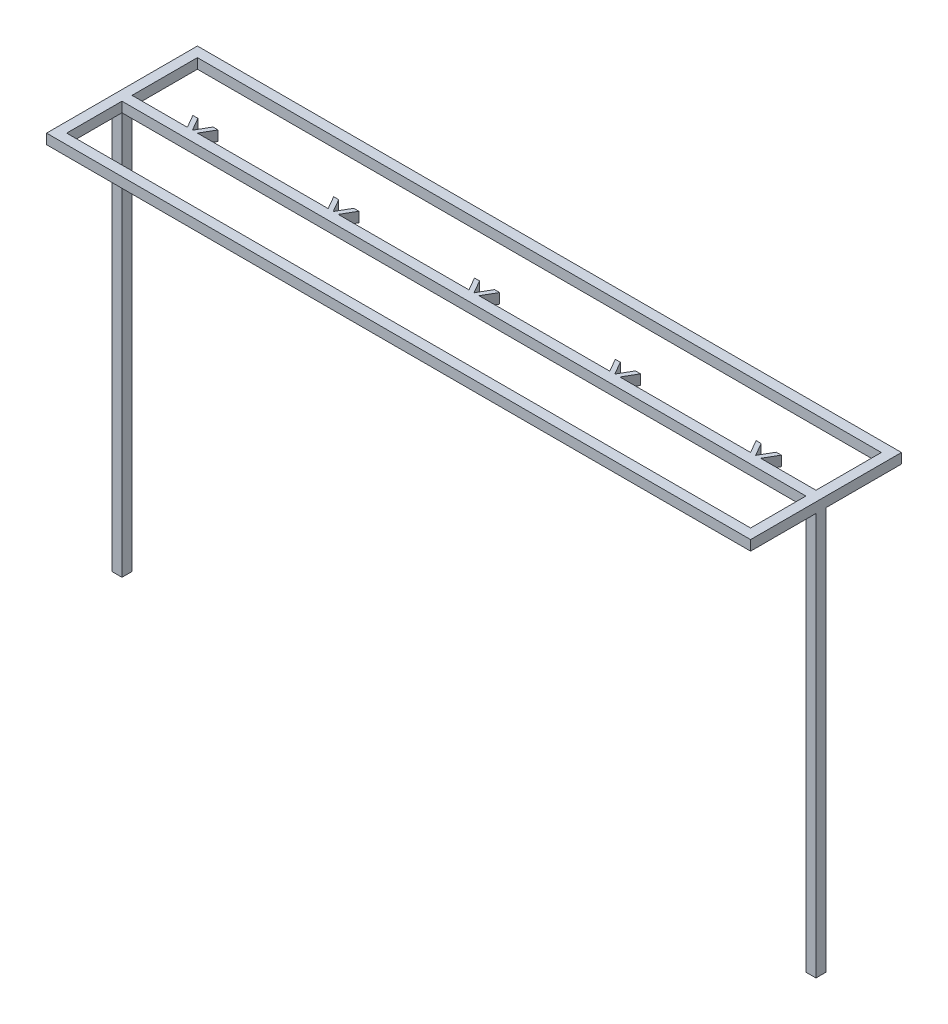
from build123d import *

# Parameters (mm, degrees)
SKETCH1_W           = 700
SKETCH1_H           = 150
BOSS_EXTRUDE1_DEPTH = 10
SKETCH2_W           = 680
SKETCH2_H           = 130
CUT_EXTRUDE1_DEPTH  = 10
SKETCH3_W           = 680
SKETCH3_H           = 10
BOSS_EXTRUDE2_DEPTH = 10
BOSS_EXTRUDE3_DEPTH = 10
SKETCH5_W           = 10
SKETCH5_H           = 10
BOSS_EXTRUDE4_DEPTH = 400


with BuildPart() as part:
    # Sketch1 → Boss-Extrude1 (new body)
    with BuildSketch(Plane(origin=(0, 0, 0), x_dir=(1, 0, 0), z_dir=(0, 1, 0))):
        Rectangle(SKETCH1_W, SKETCH1_H)
    extrude(amount=BOSS_EXTRUDE1_DEPTH)

    # Sketch2 → Cut-Extrude1 (cut)
    with BuildSketch(Plane(origin=(0, 10, 0), x_dir=(1, 0, 0), z_dir=(0, 1, 0))):
        Rectangle(SKETCH2_W, SKETCH2_H)
    extrude(amount=-CUT_EXTRUDE1_DEPTH, mode=Mode.SUBTRACT)

    # Sketch3 → Boss-Extrude2 (add)
    with BuildSketch(Plane(origin=(0, 10, 0), x_dir=(1, 0, 0), z_dir=(0, 1, 0))):
        with Locations((0, -5)):
            Rectangle(SKETCH3_W, SKETCH3_H)
    extrude(amount=-BOSS_EXTRUDE2_DEPTH)

    # Sketch4 → Boss-Extrude3 (add)
    with BuildSketch(Plane(origin=(0, 0, 0), x_dir=(1, 0, 0), z_dir=(0, 1, 0))):
        Polygon((5, 0), (0, 0), (7.5, 12.990381057), (12.5, 12.990381057), align=None)
        Polygon((140, 0), (147.5, 12.990381057), (152.5, 12.990381057), (145, 0), align=None)
        Polygon((140, 0), (132.5, 12.990381057), (127.5, 12.990381057), (135, 0), align=None)
        Polygon((0, 0), (-7.5, 12.990381057), (-12.5, 12.990381057), (-5, 0), align=None)
        Polygon((-140, 0), (-132.5, 12.990381057), (-127.5, 12.990381057), (-135, 0), align=None)
        Polygon((-140, 0), (-147.5, 12.990381057), (-152.5, 12.990381057), (-145, 0), align=None)
        Polygon((-280, 0), (-272.5, 12.990381057), (-267.5, 12.990381057), (-275, 0), align=None)
        Polygon((-280, 0), (-287.5, 12.990381057), (-292.5, 12.990381057), (-285, 0), align=None)
        Polygon((280, 0), (272.5, 12.990381057), (267.5, 12.990381057), (275, 0), align=None)
        Polygon((280, 0), (287.5, 12.990381057), (292.5, 12.990381057), (285, 0), align=None)
    extrude(amount=BOSS_EXTRUDE3_DEPTH)

    # Sketch5 → Boss-Extrude4 (add)
    with BuildSketch(Plane(origin=(0, 0, 0), x_dir=(1, 0, 0), z_dir=(0, 1, 0))):
        with Locations((-345, -5)):
            Rectangle(SKETCH5_W, SKETCH5_H)
        with Locations((345, -5)):
            Rectangle(SKETCH5_W, SKETCH5_H)
    extrude(amount=-BOSS_EXTRUDE4_DEPTH)


solid = part.part
